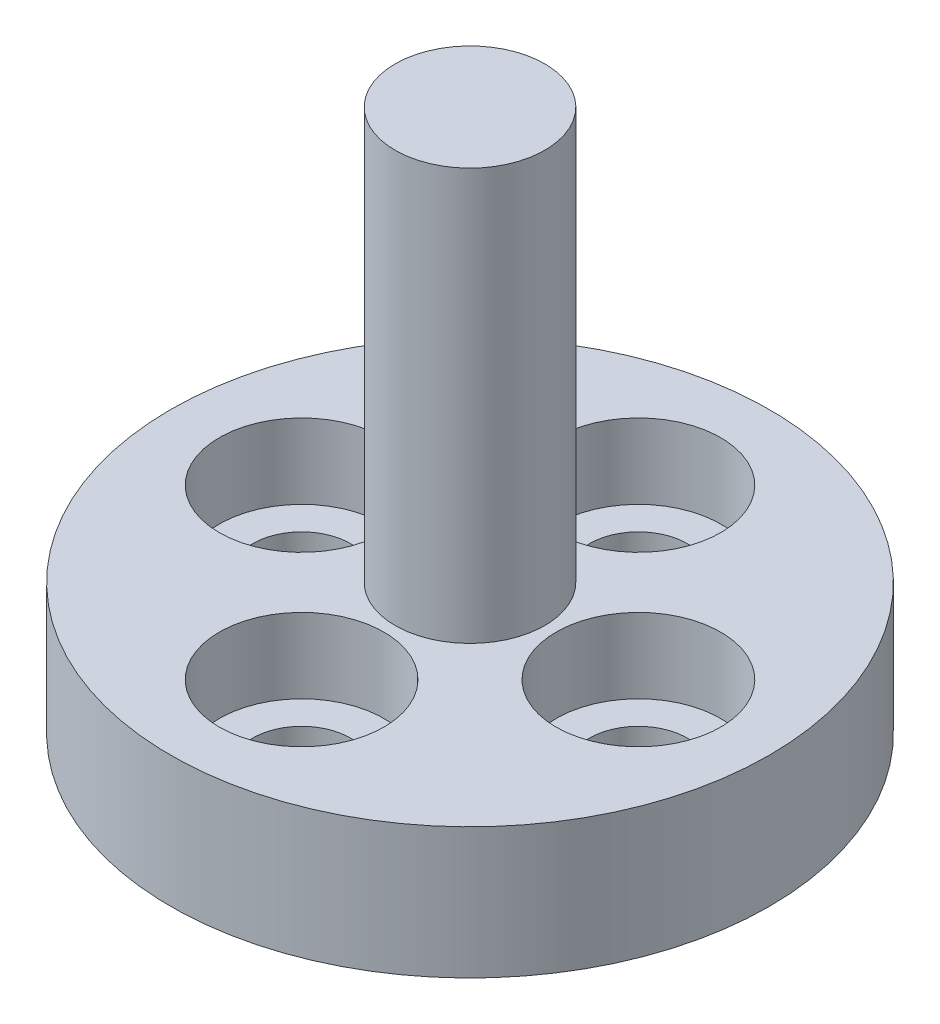
from build123d import *

# Parameters (mm, degrees)
CBORE_FOR_M2_SHCS1_D           = 2.6
CBORE_FOR_M2_SHCS1_DEPTH       = 5
CBORE_FOR_M2_SHCS1_CBORE_D     = 4.4
CBORE_FOR_M2_SHCS1_CBORE_DEPTH = 2
CBORE_FOR_M2_SHCS1_TIP         = 0.781118805


with BuildPart() as part:
    # Sketch1 → Revolve1 (revolve)
    with BuildSketch(Plane.XY):
        Polygon((0, 0), (8, 0), (8, 3.5), (2, 3.5), (2, 14.5), (0, 14.5), align=None)
    revolve(axis=Axis((0, 14.5, 0), (0, -1, 0)))

    # CBORE for M2 SHCS1
    with Locations(Plane(origin=(-4.5, 3.5, 0), x_dir=(1, 0, 0), z_dir=(0, 1, 0))):
        with Locations((0, 0), (4.5, 4.5), (9, 0), (4.5, -4.5)):
            CounterBoreHole(CBORE_FOR_M2_SHCS1_D / 2, CBORE_FOR_M2_SHCS1_CBORE_D / 2, CBORE_FOR_M2_SHCS1_CBORE_DEPTH, depth=CBORE_FOR_M2_SHCS1_DEPTH)
            with Locations((0, 0, -(CBORE_FOR_M2_SHCS1_DEPTH + CBORE_FOR_M2_SHCS1_TIP / 2))):  # 118° drill point
                Cone(0, CBORE_FOR_M2_SHCS1_D / 2, CBORE_FOR_M2_SHCS1_TIP, mode=Mode.SUBTRACT)


solid = part.part
